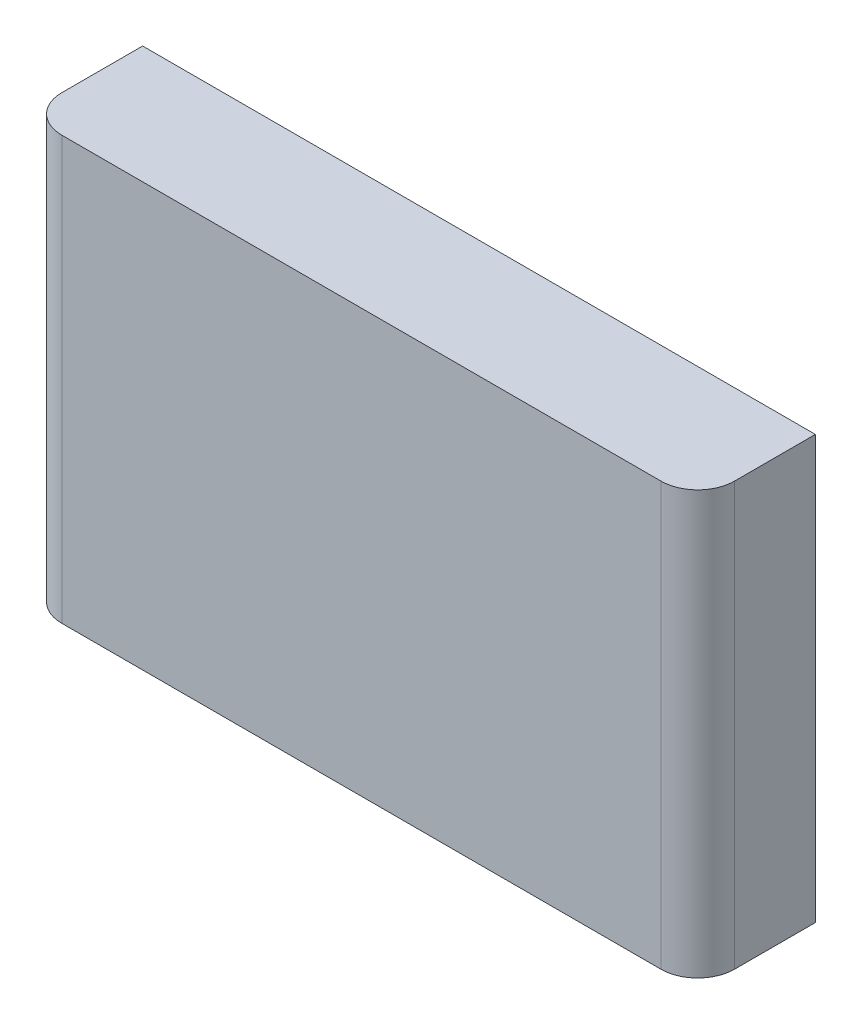
from build123d import *

# Parameters (mm, degrees)
SKETCH1_W           = 91.5
SKETCH1_H           = 57.5
BOSS_EXTRUDE1_DEPTH = 16
FILLET1_R           = 5


with BuildPart() as part:
    # Sketch1 → Boss-Extrude1 (new body)
    with BuildSketch(Plane.XY):
        Rectangle(SKETCH1_W, SKETCH1_H)
    extrude(amount=BOSS_EXTRUDE1_DEPTH)

    # Fillet1
    fillet1_edges = [part.edges().sort_by_distance(p)[0] for p in [
        (45.75, 0, 16),
        (-45.75, 0, 16),
    ]]
    fillet(fillet1_edges, radius=FILLET1_R)


solid = part.part
